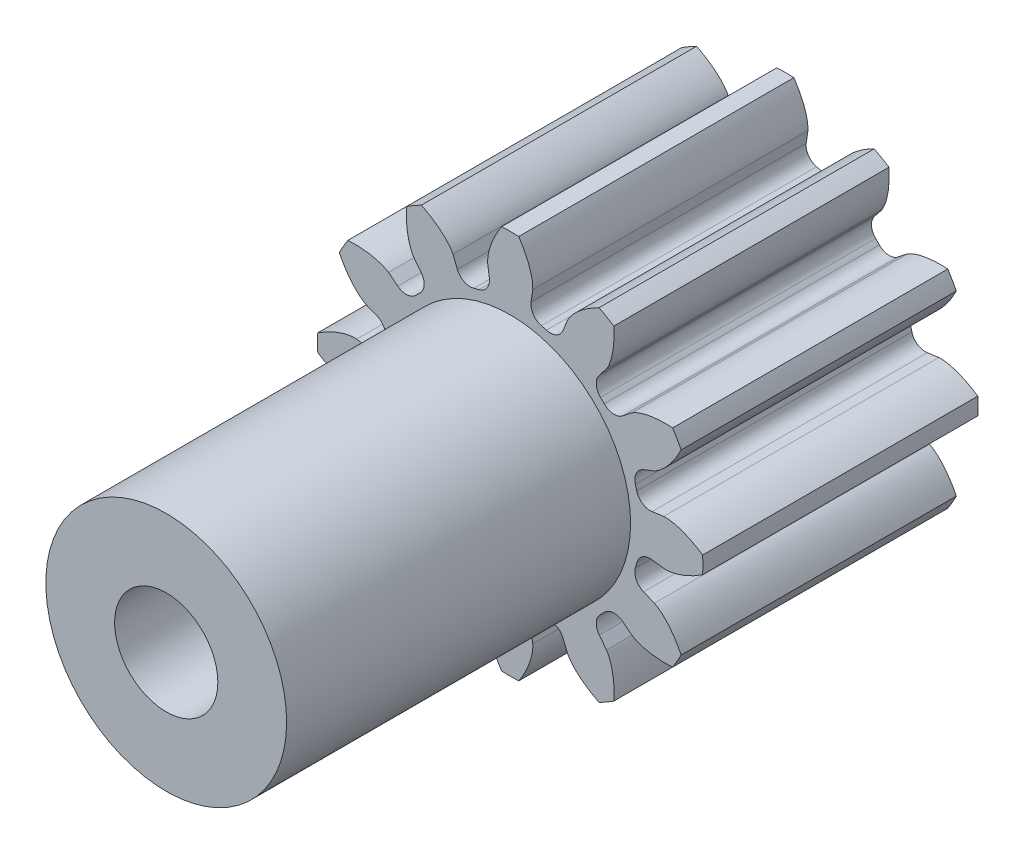
from build123d import *

# Parameters (mm, degrees)
BOSS_EXTRUDE1_DEPTH          = 8
SKETCH2_W                    = 3.5
SKETCH2_H                    = 10
F_3_0_3_DIAMETER_HOLE1_D     = 3
F_3_0_3_DIAMETER_HOLE1_DEPTH = 18
FILLET1_R                    = 0.4
SKETCH5_R                    = 1.25
CUT_EXTRUDE1_DEPTH           = 10


with BuildPart() as part:
    # Sketch1 → Boss-Extrude1 (new body)
    with BuildSketch(Plane(origin=(0, 0, 0), x_dir=(-1, 0, 0), z_dir=(0, 0, -1))):
        with BuildLine():
            Line((-2.352378115, -2.970581399), (-2.798860879, -3.537118851))
            add(Edge.make_bspline(
                [(-2.798860879, -3.537118851), (-3.065797124, -3.947453044), (-3.012261762, -4.720834574)],
                knots=[0.532295358, 0.532295358, 0.532295358, 1.591040203, 1.591040203, 1.591040203], degree=2, weights=[1, 0.863124162, 1]))
            ThreePointArc((-3.012261762, -4.720834574), (-2.8, -4.849742261), (-2.582231787, -4.969112496))
            add(Edge.make_bspline(
                [(-2.582231787, -4.969112496), (-1.885696054, -4.628784714), (-1.663804342, -4.192444048)],
                knots=[1.55055245, 1.55055245, 1.55055245, 2.609297296, 2.609297296, 2.609297296], degree=2, weights=[1, 0.863124162, 1]))
            Line((-1.663804342, -4.192444048), (-1.396409898, -3.522509906))
            ThreePointArc((-1.396409898, -3.522509906), (-0.980717126, -3.660086141), (-0.551928507, -3.748788013))
            Line((-0.551928507, -3.748788013), (-0.655325197, -4.462665221))
            add(Edge.make_bspline(
                [(-0.655325197, -4.462665221), (-0.68133167, -4.951493178), (-0.248277921, -5.594493549)],
                knots=[0.532295358, 0.532295358, 0.532295358, 1.591040203, 1.591040203, 1.591040203], degree=2, weights=[1, 0.863124162, 1]))
            ThreePointArc((-0.248277921, -5.594493549), (0, -5.6), (0.248277921, -5.594493549))
            add(Edge.make_bspline(
                [(0.248277921, -5.594493549), (0.68133167, -4.951493178), (0.655325197, -4.462665221)],
                knots=[1.55055245, 1.55055245, 1.55055245, 2.609297296, 2.609297296, 2.609297296], degree=2, weights=[1, 0.863124162, 1]))
            Line((0.655325197, -4.462665221), (0.551928507, -3.748788013))
            ThreePointArc((0.551928507, -3.748788013), (0.980717126, -3.660086141), (1.396409898, -3.522509906))
            Line((1.396409898, -3.522509906), (1.663804342, -4.192444048))
            add(Edge.make_bspline(
                [(1.663804342, -4.192444048), (1.885696054, -4.628784714), (2.582231787, -4.969112496)],
                knots=[3.673888012, 3.673888012, 3.673888012, 4.732632857, 4.732632857, 4.732632857], degree=2, weights=[1, 0.863124162, 1]))
            ThreePointArc((2.582231787, -4.969112496), (2.8, -4.849742261), (3.012261762, -4.720834574))
            add(Edge.make_bspline(
                [(3.012261762, -4.720834574), (3.065797124, -3.947453044), (2.798860879, -3.537118851)],
                knots=[1.55055245, 1.55055245, 1.55055245, 2.609297296, 2.609297296, 2.609297296], degree=2, weights=[1, 0.863124162, 1]))
            Line((2.798860879, -3.537118851), (2.352378115, -2.970581399))
            ThreePointArc((2.352378115, -2.970581399), (2.679369015, -2.679369015), (2.970581399, -2.352378115))
            Line((2.970581399, -2.352378115), (3.537118851, -2.798860879))
            add(Edge.make_bspline(
                [(3.537118851, -2.798860879), (3.947453044, -3.065797124), (4.720834574, -3.012261762)],
                knots=[0.532295358, 0.532295358, 0.532295358, 1.591040203, 1.591040203, 1.591040203], degree=2, weights=[1, 0.863124162, 1]))
            ThreePointArc((4.720834574, -3.012261762), (4.849742261, -2.8), (4.969112496, -2.582231787))
            add(Edge.make_bspline(
                [(4.969112496, -2.582231787), (4.628784714, -1.885696054), (4.192444048, -1.663804342)],
                knots=[1.55055245, 1.55055245, 1.55055245, 2.609297296, 2.609297296, 2.609297296], degree=2, weights=[1, 0.863124162, 1]))
            Line((4.192444048, -1.663804342), (3.522509906, -1.396409898))
            ThreePointArc((3.522509906, -1.396409898), (3.660086141, -0.980717126), (3.748788013, -0.551928507))
            Line((3.748788013, -0.551928507), (4.462665221, -0.655325197))
            add(Edge.make_bspline(
                [(4.462665221, -0.655325197), (4.951493178, -0.68133167), (5.594493549, -0.248277921)],
                knots=[0.532295358, 0.532295358, 0.532295358, 1.591040203, 1.591040203, 1.591040203], degree=2, weights=[1, 0.863124162, 1]))
            ThreePointArc((5.594493549, -0.248277921), (5.6, 0), (5.594493549, 0.248277921))
            add(Edge.make_bspline(
                [(5.594493549, 0.248277921), (4.951493178, 0.68133167), (4.462665221, 0.655325197)],
                knots=[4.692145104, 4.692145104, 4.692145104, 5.750889949, 5.750889949, 5.750889949], degree=2, weights=[1, 0.863124162, 1]))
            Line((4.462665221, 0.655325197), (3.748788013, 0.551928507))
            ThreePointArc((3.748788013, 0.551928507), (3.660086141, 0.980717126), (3.522509906, 1.396409898))
            Line((3.522509906, 1.396409898), (4.192444048, 1.663804342))
            add(Edge.make_bspline(
                [(4.192444048, 1.663804342), (4.628784714, 1.885696054), (4.969112496, 2.582231787)],
                knots=[3.673888012, 3.673888012, 3.673888012, 4.732632857, 4.732632857, 4.732632857], degree=2, weights=[1, 0.863124162, 1]))
            ThreePointArc((4.969112496, 2.582231787), (4.849742261, 2.8), (4.720834574, 3.012261762))
            add(Edge.make_bspline(
                [(4.720834574, 3.012261762), (3.947453044, 3.065797124), (3.537118851, 2.798860879)],
                knots=[1.55055245, 1.55055245, 1.55055245, 2.609297296, 2.609297296, 2.609297296], degree=2, weights=[1, 0.863124162, 1]))
            Line((3.537118851, 2.798860879), (2.970581399, 2.352378115))
            ThreePointArc((2.970581399, 2.352378115), (2.679369015, 2.679369015), (2.352378115, 2.970581399))
            Line((2.352378115, 2.970581399), (2.798860879, 3.537118851))
            add(Edge.make_bspline(
                [(2.798860879, 3.537118851), (3.065797124, 3.947453044), (3.012261762, 4.720834574)],
                knots=[3.673888012, 3.673888012, 3.673888012, 4.732632857, 4.732632857, 4.732632857], degree=2, weights=[1, 0.863124162, 1]))
            ThreePointArc((3.012261762, 4.720834574), (2.8, 4.849742261), (2.582231787, 4.969112496))
            add(Edge.make_bspline(
                [(2.582231787, 4.969112496), (1.885696054, 4.628784714), (1.663804342, 4.192444048)],
                knots=[4.692145104, 4.692145104, 4.692145104, 5.750889949, 5.750889949, 5.750889949], degree=2, weights=[1, 0.863124162, 1]))
            Line((1.663804342, 4.192444048), (1.396409898, 3.522509906))
            ThreePointArc((1.396409898, 3.522509906), (0.980717126, 3.660086141), (0.551928507, 3.748788013))
            Line((0.551928507, 3.748788013), (0.655325197, 4.462665221))
            add(Edge.make_bspline(
                [(0.655325197, 4.462665221), (0.68133167, 4.951493178), (0.248277921, 5.594493549)],
                knots=[3.673888012, 3.673888012, 3.673888012, 4.732632857, 4.732632857, 4.732632857], degree=2, weights=[1, 0.863124162, 1]))
            ThreePointArc((0.248277921, 5.594493549), (0, 5.6), (-0.248277921, 5.594493549))
            add(Edge.make_bspline(
                [(-0.248277921, 5.594493549), (-0.68133167, 4.951493178), (-0.655325197, 4.462665221)],
                knots=[4.692145104, 4.692145104, 4.692145104, 5.750889949, 5.750889949, 5.750889949], degree=2, weights=[1, 0.863124162, 1]))
            Line((-0.655325197, 4.462665221), (-0.551928507, 3.748788013))
            ThreePointArc((-0.551928507, 3.748788013), (-0.980717126, 3.660086141), (-1.396409898, 3.522509906))
            Line((-1.396409898, 3.522509906), (-1.663804342, 4.192444048))
            add(Edge.make_bspline(
                [(-1.663804342, 4.192444048), (-1.885696054, 4.628784714), (-2.582231787, 4.969112496)],
                knots=[3.673888012, 3.673888012, 3.673888012, 4.732632857, 4.732632857, 4.732632857], degree=2, weights=[1, 0.863124162, 1]))
            ThreePointArc((-2.582231787, 4.969112496), (-2.8, 4.849742261), (-3.012261762, 4.720834574))
            add(Edge.make_bspline(
                [(-3.012261762, 4.720834574), (-3.065797124, 3.947453044), (-2.798860879, 3.537118851)],
                knots=[4.692145104, 4.692145104, 4.692145104, 5.750889949, 5.750889949, 5.750889949], degree=2, weights=[1, 0.863124162, 1]))
            Line((-2.798860879, 3.537118851), (-2.352378115, 2.970581399))
            ThreePointArc((-2.352378115, 2.970581399), (-2.679369015, 2.679369015), (-2.970581399, 2.352378115))
            Line((-2.970581399, 2.352378115), (-3.537118851, 2.798860879))
            add(Edge.make_bspline(
                [(-3.537118851, 2.798860879), (-3.947453044, 3.065797124), (-4.720834574, 3.012261762)],
                knots=[3.673888012, 3.673888012, 3.673888012, 4.732632857, 4.732632857, 4.732632857], degree=2, weights=[1, 0.863124162, 1]))
            ThreePointArc((-4.720834574, 3.012261762), (-4.849742261, 2.8), (-4.969112496, 2.582231787))
            add(Edge.make_bspline(
                [(-4.969112496, 2.582231787), (-4.628784714, 1.885696054), (-4.192444048, 1.663804342)],
                knots=[4.692145104, 4.692145104, 4.692145104, 5.750889949, 5.750889949, 5.750889949], degree=2, weights=[1, 0.863124162, 1]))
            Line((-4.192444048, 1.663804342), (-3.522509906, 1.396409898))
            ThreePointArc((-3.522509906, 1.396409898), (-3.660086141, 0.980717126), (-3.748788013, 0.551928507))
            Line((-3.748788013, 0.551928507), (-4.462665221, 0.655325197))
            add(Edge.make_bspline(
                [(-4.462665221, 0.655325197), (-4.951493178, 0.68133167), (-5.594493549, 0.248277921)],
                knots=[3.673888012, 3.673888012, 3.673888012, 4.732632857, 4.732632857, 4.732632857], degree=2, weights=[1, 0.863124162, 1]))
            ThreePointArc((-5.594493549, 0.248277921), (-5.6, 0), (-5.594493549, -0.248277921))
            add(Edge.make_bspline(
                [(-5.594493549, -0.248277921), (-4.951493178, -0.68133167), (-4.462665221, -0.655325197)],
                knots=[1.55055245, 1.55055245, 1.55055245, 2.609297296, 2.609297296, 2.609297296], degree=2, weights=[1, 0.863124162, 1]))
            Line((-4.462665221, -0.655325197), (-3.748788013, -0.551928507))
            ThreePointArc((-3.748788013, -0.551928507), (-3.660086141, -0.980717126), (-3.522509906, -1.396409898))
            Line((-3.522509906, -1.396409898), (-4.192444048, -1.663804342))
            add(Edge.make_bspline(
                [(-4.192444048, -1.663804342), (-4.628784714, -1.885696054), (-4.969112496, -2.582231787)],
                knots=[0.532295358, 0.532295358, 0.532295358, 1.591040203, 1.591040203, 1.591040203], degree=2, weights=[1, 0.863124162, 1]))
            ThreePointArc((-4.969112496, -2.582231787), (-4.849742261, -2.8), (-4.720834574, -3.012261762))
            add(Edge.make_bspline(
                [(-4.720834574, -3.012261762), (-3.947453044, -3.065797124), (-3.537118851, -2.798860879)],
                knots=[1.55055245, 1.55055245, 1.55055245, 2.609297296, 2.609297296, 2.609297296], degree=2, weights=[1, 0.863124162, 1]))
            Line((-3.537118851, -2.798860879), (-2.970581399, -2.352378115))
            ThreePointArc((-2.970581399, -2.352378115), (-2.679369015, -2.679369015), (-2.352378115, -2.970581399))
        make_face()
    extrude(amount=-BOSS_EXTRUDE1_DEPTH)

    # Sketch2 → Revolve1 (revolve)
    with BuildSketch(Plane(origin=(0, 0, 0), x_dir=(1, 0, 0), z_dir=(0, 1, 0))):
        with Locations((1.75, -13)):
            Rectangle(SKETCH2_W, SKETCH2_H)
    revolve(axis=Axis((0, 0, 8), (0, 0, 1)))

    # Ø3.0 (3) Diameter Hole1
    with Locations(Plane.XY.offset(18)):
        with Locations((0, 0)):
            Hole(F_3_0_3_DIAMETER_HOLE1_D / 2, depth=F_3_0_3_DIAMETER_HOLE1_DEPTH)

    # Fillet1
    fillet1_edges = [part.edges().sort_by_distance(p)[0] for p in [
        (2.970581399, -2.352378115, 4),
        (3.522509906, -1.396409898, 4),
        (3.748788013, -0.551928507, 4),
        (3.748788013, 0.551928507, 4),
        (3.522509906, 1.396409898, 4),
        (2.970581399, 2.352378115, 4),
        (2.352378115, 2.970581399, 4),
        (1.396409898, 3.522509906, 4),
        (0.551928507, 3.748788013, 4),
        (-0.551928507, 3.748788013, 4),
        (-1.396409898, 3.522509906, 4),
        (-2.352378115, 2.970581399, 4),
        (-2.970581399, 2.352378115, 4),
        (-3.522509906, 1.396409898, 4),
        (-3.748788013, 0.551928507, 4),
        (-3.748788013, -0.551928507, 4),
        (-3.522509906, -1.396409898, 4),
        (-2.970581399, -2.352378115, 4),
        (-2.352378115, -2.970581399, 4),
        (-1.396409898, -3.522509906, 4),
        (-0.551928507, -3.748788013, 4),
        (0.551928507, -3.748788013, 4),
        (1.396409898, -3.522509906, 4),
        (2.352378115, -2.970581399, 4),
    ]]
    fillet(fillet1_edges, radius=FILLET1_R)

    # Sketch5 → Cut-Extrude1 (cut)
    with BuildSketch(Plane(origin=(0, 0, 0), x_dir=(1, 0, 0), z_dir=(0, 1, 0))):
        with Locations((0, -14)):
            Circle(SKETCH5_R)
    extrude(amount=-CUT_EXTRUDE1_DEPTH, mode=Mode.SUBTRACT)


solid = part.part
